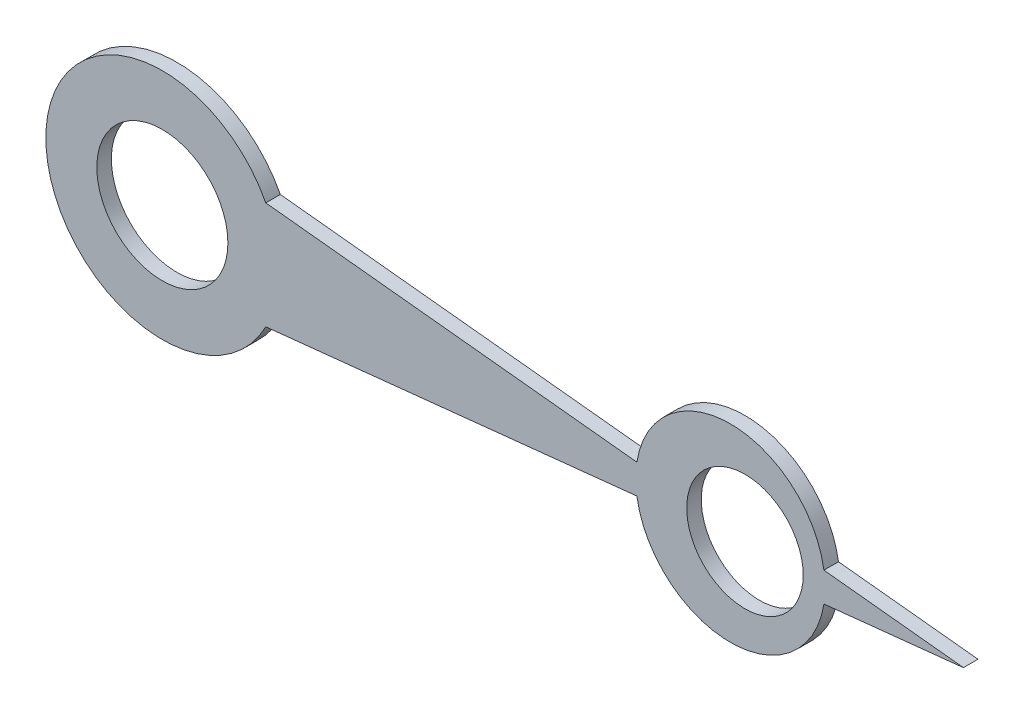
from build123d import *

# Parameters (mm, degrees)
BOSS_EXTRUDE1_START = 19
SKETCH2_R           = 4.5
SKETCH2_R_2         = 4
BOSS_EXTRUDE1_DEPTH = 1


with BuildPart() as part:
    # Sketch2 → Boss-Extrude1 (new body)
    with BuildSketch(Plane.XY.offset(BOSS_EXTRUDE1_START)):
        with BuildLine():
            Line((55, 0), (45.421564163, -1.006734174))
            ThreePointArc((45.421564163, -1.006734174), (39, -6.5), (32.578435837, -1.006734174))
            Line((32.578435837, -1.006734174), (7.101007974, -3.684519746))
            ThreePointArc((7.101007974, -3.684519746), (-8, 0), (7.101007974, 3.684519746))
            Line((7.101007974, 3.684519746), (32.578435837, 1.006734174))
            ThreePointArc((32.578435837, 1.006734174), (39, 6.5), (45.421564163, 1.006734174))
            Line((45.421564163, 1.006734174), (55, 0))
        make_face()
        Circle(SKETCH2_R, mode=Mode.SUBTRACT)
        with Locations((40, 0)):
            Circle(SKETCH2_R_2, mode=Mode.SUBTRACT)
    extrude(amount=BOSS_EXTRUDE1_DEPTH)


solid = part.part
